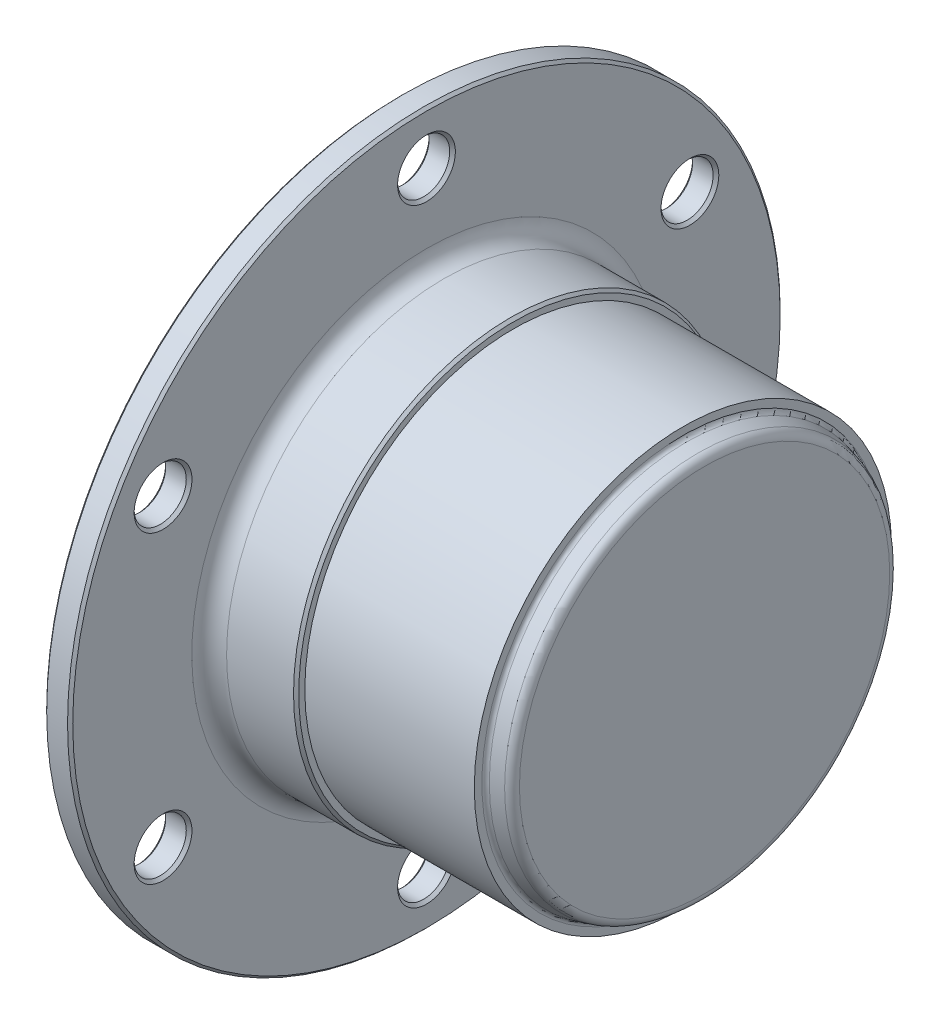
from build123d import *

# Parameters (mm, degrees)
SKETCH2_R                         = 25
BOSS_EXTRUDE1_DEPTH               = 7.7
SKETCH3_R                         = 25
BOSS_EXTRUDE2_DEPTH               = 0.3
BOSS_EXTRUDE2_TAPER               = 44.999999949
SKETCH4_R                         = 24
BOSS_EXTRUDE3_DEPTH               = 19.5
SKETCH5_R                         = 22.741139955
BOSS_EXTRUDE4_DEPTH               = 2.5
BOSS_EXTRUDE4_TAPER               = 15.02708836
F_6_0_6_DIAMETER_HOLE1_AT_2_COUNT = 2
F_6_0_6_DIAMETER_HOLE1_AT_2_PITCH = 35
F_6_0_6_DIAMETER_HOLE1_AT_3_COUNT = 2
F_6_0_6_DIAMETER_HOLE1_AT_3_PITCH = 60.621778265
F_6_0_6_DIAMETER_HOLE1_AT_4_COUNT = 2
F_6_0_6_DIAMETER_HOLE1_AT_4_PITCH = 70
F_6_0_6_DIAMETER_HOLE1_AT_5_COUNT = 2
F_6_0_6_DIAMETER_HOLE1_AT_5_PITCH = 60.621778265
F_6_0_6_DIAMETER_HOLE1_AT_6_COUNT = 2
F_6_0_6_DIAMETER_HOLE1_AT_6_PITCH = 35
CHAMFER1_SIZE                     = 0.3
FILLET1_R                         = 0.5
FILLET2_R                         = 1


with BuildPart() as part:
    # Sketch1 → Revolve1 (revolve)
    with BuildSketch(Plane.XY):
        with BuildLine():
            Line((0, 41), (0, 0))
            Line((0, 0), (5, 0))
            Line((5, 0), (5, 25))
            ThreePointArc((5, 25), (3.585786438, 25.585786438), (3, 27))
            Line((3, 27), (3, 41))
            Line((3, 41), (0, 41))
        make_face()
    revolve(axis=Axis((0, 0, 0), (1, 0, 0)))

    # Sketch2 → Boss-Extrude1 (add)
    with BuildSketch(Plane(origin=(5, 0, 0), x_dir=(0, 0, -1), z_dir=(1, 0, 0))):
        Circle(SKETCH2_R)
    extrude(amount=BOSS_EXTRUDE1_DEPTH)

    # Sketch3 → Boss-Extrude2 (add)
    with BuildSketch(Plane(origin=(12.7, 0, 0), x_dir=(0, 0, -1), z_dir=(1, 0, 0))):
        Circle(SKETCH3_R)
    extrude(amount=BOSS_EXTRUDE2_DEPTH, taper=BOSS_EXTRUDE2_TAPER)

    # Sketch4 → Boss-Extrude3 (add)
    with BuildSketch(Plane(origin=(13, 0, 0), x_dir=(0, 0, -1), z_dir=(1, 0, 0))):
        Circle(SKETCH4_R)
    extrude(amount=BOSS_EXTRUDE3_DEPTH)

    # Sketch5 → Boss-Extrude4 (add)
    with BuildSketch(Plane(origin=(32.5, 0, 0), x_dir=(0, 0, -1), z_dir=(1, 0, 0))):
        Circle(SKETCH5_R)
    extrude(amount=BOSS_EXTRUDE4_DEPTH, taper=BOSS_EXTRUDE4_TAPER)

    # Sketch6 → Ø6.0 (6) Diameter Hole1 (revolve, cut)
    with BuildSketch(Plane(origin=(3, -17.5, 30.310889132), x_dir=(0, 0, -1), z_dir=(0, 1, 0))):
        Polygon((0, 0), (0, 3), (3, 3), (3, 0.326896118), (3.326896118, 0), align=None)
    f_6_0_6_diameter_hole1 = revolve(axis=Axis((9.35, -17.5, 30.310889132), (-1, 0, 0)), mode=Mode.SUBTRACT)

    # Ø6.0 (6) Diameter Hole1 at 2: Ø6.0 (6) Diameter Hole1 ×2
    with Locations(*[(0, i * F_6_0_6_DIAMETER_HOLE1_AT_2_PITCH, 0) for i in range(1, F_6_0_6_DIAMETER_HOLE1_AT_2_COUNT)]):
        add(f_6_0_6_diameter_hole1, mode=Mode.SUBTRACT)

    # Ø6.0 (6) Diameter Hole1 at 3: Ø6.0 (6) Diameter Hole1 ×2
    with Locations(*[Vector(0, 0.866025404, -0.5) * (i * F_6_0_6_DIAMETER_HOLE1_AT_3_PITCH) for i in range(1, F_6_0_6_DIAMETER_HOLE1_AT_3_COUNT)]):
        add(f_6_0_6_diameter_hole1, mode=Mode.SUBTRACT)

    # Ø6.0 (6) Diameter Hole1 at 4: Ø6.0 (6) Diameter Hole1 ×2
    with Locations(*[Vector(0, 0.5, -0.866025404) * (i * F_6_0_6_DIAMETER_HOLE1_AT_4_PITCH) for i in range(1, F_6_0_6_DIAMETER_HOLE1_AT_4_COUNT)]):
        add(f_6_0_6_diameter_hole1, mode=Mode.SUBTRACT)

    # Ø6.0 (6) Diameter Hole1 at 5: Ø6.0 (6) Diameter Hole1 ×2
    with Locations(*[(0, 0, -i * F_6_0_6_DIAMETER_HOLE1_AT_5_PITCH) for i in range(1, F_6_0_6_DIAMETER_HOLE1_AT_5_COUNT)]):
        add(f_6_0_6_diameter_hole1, mode=Mode.SUBTRACT)

    # Ø6.0 (6) Diameter Hole1 at 6: Ø6.0 (6) Diameter Hole1 ×2
    with Locations(*[Vector(0, -0.5, -0.866025404) * (i * F_6_0_6_DIAMETER_HOLE1_AT_6_PITCH) for i in range(1, F_6_0_6_DIAMETER_HOLE1_AT_6_COUNT)]):
        add(f_6_0_6_diameter_hole1, mode=Mode.SUBTRACT)

    # Chamfer1
    chamfer1_edges = [part.edges().sort_by_distance(p)[0] for p in [
        (0, -35, 3),
        (0, -17.5, -27.310889132),
        (0, 17.5, -27.310889132),
        (0, -41, 0),
        (0, 35, 3),
        (0, 17.5, 33.310889132),
        (0, -17.5, 33.310889132),
        (3, -41, 0),
    ]]
    chamfer(chamfer1_edges, length=CHAMFER1_SIZE)

    # Fillet1
    fillet1_edges = [part.edges().sort_by_distance(p)[0] for p in [
        (32.5, 0, 22.741139955),
    ]]
    fillet(fillet1_edges, radius=FILLET1_R)

    # Fillet2
    fillet2_edges = [part.edges().sort_by_distance(p)[0] for p in [
        (35, 0, 22.07),
    ]]
    fillet(fillet2_edges, radius=FILLET2_R)


solid = part.part
